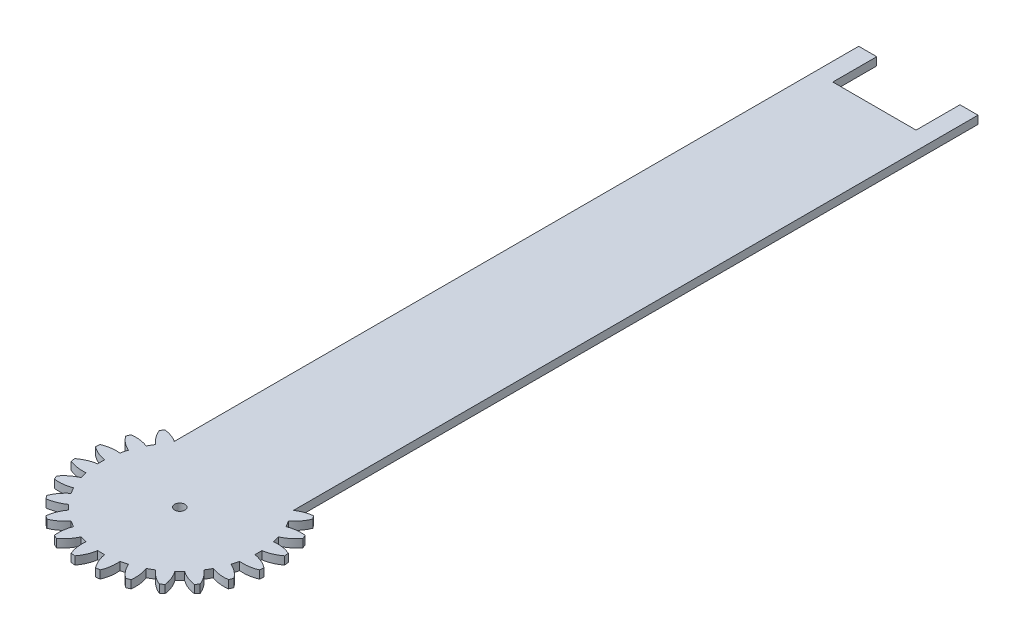
from build123d import *

# Parameters (mm, degrees)
SKETCH1_R           = 1.4
BOSS_EXTRUDE2_DEPTH = 2.2


with BuildPart() as part:
    # Sketch1 → Boss-Extrude2 (new body)
    with BuildSketch(Plane(origin=(0, 0, 0), x_dir=(1, 0, 0), z_dir=(0, 1, 0))):
        with BuildLine():
            Line((16.3, 94), (11.375, 94))
            Line((11.375, 94), (11.375, 82))
            Line((11.375, 82), (-11.375, 82))
            Line((-11.375, 82), (-11.375, 94))
            Line((-11.375, 94), (-16.3, 94))
            Line((-16.3, 94), (-16.3, -93.009457189))
            ThreePointArc((-16.3, -93.009457189), (-18.198030993, -92.065396391), (-20.256978495, -91.560908909))
            ThreePointArc((-20.256978495, -91.560908909), (-20.608541379, -92.008832104), (-20.950210791, -92.464346827))
            ThreePointArc((-20.950210791, -92.464346827), (-19.767163473, -94.547256661), (-18.105269554, -96.272429968))
            ThreePointArc((-18.105269554, -96.272429968), (-18.600034687, -97.087129259), (-19.058202403, -97.922958078))
            ThreePointArc((-19.058202403, -97.922958078), (-21.383193272, -97.34630238), (-23.778569761, -97.363208265))
            ThreePointArc((-23.778569761, -97.363208265), (-24.002222377, -97.886860017), (-24.214353801, -98.415284003))
            ThreePointArc((-24.214353801, -98.415284003), (-22.532521108, -100.121025228), (-20.480747143, -101.357284883))
            ThreePointArc((-20.480747143, -101.357284883), (-20.747793871, -102.272278608), (-20.974021483, -103.198209782))
            ThreePointArc((-20.974021483, -103.198209782), (-23.369039687, -103.242955066), (-25.678420136, -103.879253953))
            ThreePointArc((-25.678420136, -103.879253953), (-25.758920927, -104.442948261), (-25.827057957, -105.008270289))
            ThreePointArc((-25.827057957, -105.008270289), (-23.761054008, -106.220599459), (-21.459225003, -106.88369641))
            ThreePointArc((-21.459225003, -106.88369641), (-21.480354532, -107.836629259), (-21.459225003, -108.789562107))
            ThreePointArc((-21.459225003, -108.789562107), (-23.761054008, -109.452659058), (-25.827057957, -110.664988228))
            ThreePointArc((-25.827057957, -110.664988228), (-25.758920927, -111.230310256), (-25.678420136, -111.794004564))
            ThreePointArc((-25.678420136, -111.794004564), (-23.369039687, -112.430303451), (-20.974021484, -112.475048735))
            ThreePointArc((-20.974021484, -112.475048735), (-20.747793871, -113.400979909), (-20.480747144, -114.315973634))
            ThreePointArc((-20.480747144, -114.315973634), (-22.532521108, -115.552233289), (-24.214353801, -117.257974514))
            ThreePointArc((-24.214353801, -117.257974514), (-24.002222377, -117.7863985), (-23.778569761, -118.310050252))
            ThreePointArc((-23.778569761, -118.310050252), (-21.383193272, -118.326956137), (-19.058202403, -117.750300439))
            ThreePointArc((-19.058202403, -117.750300439), (-18.600034687, -118.586129259), (-18.105269555, -119.40082855))
            ThreePointArc((-18.105269555, -119.40082855), (-19.767163473, -121.126001856), (-20.950210791, -123.20891169))
            ThreePointArc((-20.950210791, -123.20891169), (-20.608541379, -123.664426413), (-20.256978495, -124.112349608))
            ThreePointArc((-20.256978495, -124.112349608), (-17.938846915, -123.508710383), (-15.842327667, -122.349951835))
            ThreePointArc((-15.842327667, -122.349951835), (-15.18344322, -123.038717947), (-14.494677108, -123.697602394))
            ThreePointArc((-14.494677108, -123.697602394), (-15.653435656, -125.794121643), (-16.257074881, -128.112253222))
            ThreePointArc((-16.257074881, -128.112253222), (-15.809151686, -128.463816106), (-15.353636963, -128.805485519))
            ThreePointArc((-15.353636963, -128.805485519), (-13.270727129, -127.6224382), (-11.545553822, -125.960544282))
            ThreePointArc((-11.545553822, -125.960544282), (-10.730854531, -126.455309415), (-9.895025712, -126.91347713))
            ThreePointArc((-9.895025712, -126.91347713), (-10.47168141, -129.238467999), (-10.454775525, -131.633844488))
            ThreePointArc((-10.454775525, -131.633844488), (-9.931123773, -131.857497104), (-9.402699787, -132.069628528))
            ThreePointArc((-9.402699787, -132.069628528), (-7.696958562, -130.387795835), (-6.460698907, -128.336021871))
            ThreePointArc((-6.460698907, -128.336021871), (-5.545705182, -128.603068598), (-4.619774008, -128.829296211))
            ThreePointArc((-4.619774008, -128.829296211), (-4.575028724, -131.224314414), (-3.938729837, -133.533694863))
            ThreePointArc((-3.938729837, -133.533694863), (-3.375035529, -133.614195654), (-2.809713501, -133.682332684))
            ThreePointArc((-2.809713501, -133.682332684), (-1.597384331, -131.616328735), (-0.93428738, -129.31449973))
            ThreePointArc((-0.93428738, -129.31449973), (0.018645469, -129.335629259), (0.971578317, -129.31449973))
            ThreePointArc((0.971578317, -129.31449973), (1.634675268, -131.616328735), (2.847004438, -133.682332684))
            ThreePointArc((2.847004438, -133.682332684), (3.412326466, -133.614195654), (3.976020774, -133.533694863))
            ThreePointArc((3.976020774, -133.533694863), (4.612319661, -131.224314414), (4.657064945, -128.829296211))
            ThreePointArc((4.657064945, -128.829296211), (5.582996119, -128.603068598), (6.497989844, -128.336021871))
            ThreePointArc((6.497989844, -128.336021871), (7.734249499, -130.387795835), (9.439990724, -132.069628528))
            ThreePointArc((9.439990724, -132.069628528), (9.96841471, -131.857497104), (10.492066462, -131.633844488))
            ThreePointArc((10.492066462, -131.633844488), (10.508972347, -129.238467999), (9.932316649, -126.91347713))
            ThreePointArc((9.932316649, -126.91347713), (10.768145469, -126.455309415), (11.582844759, -125.960544282))
            ThreePointArc((11.582844759, -125.960544282), (13.308018066, -127.6224382), (15.3909279, -128.805485518))
            ThreePointArc((15.3909279, -128.805485518), (15.846442623, -128.463816106), (16.294365818, -128.112253222))
            ThreePointArc((16.294365818, -128.112253222), (15.690726593, -125.794121643), (14.531968045, -123.697602394))
            ThreePointArc((14.531968045, -123.697602394), (15.220734157, -123.038717947), (15.879618604, -122.349951835))
            ThreePointArc((15.879618604, -122.349951835), (17.976137853, -123.508710383), (20.294269432, -124.112349608))
            ThreePointArc((20.294269432, -124.112349608), (20.645832316, -123.664426413), (20.987501728, -123.20891169))
            ThreePointArc((20.987501728, -123.20891169), (19.80445441, -121.126001856), (18.142560492, -119.400828549))
            ThreePointArc((18.142560492, -119.400828549), (18.637325625, -118.586129259), (19.09549334, -117.750300439))
            ThreePointArc((19.09549334, -117.750300439), (21.420484209, -118.326956137), (23.815860698, -118.310050252))
            ThreePointArc((23.815860698, -118.310050252), (24.039513314, -117.7863985), (24.251644738, -117.257974514))
            ThreePointArc((24.251644738, -117.257974514), (22.569812045, -115.552233289), (20.518038081, -114.315973634))
            ThreePointArc((20.518038081, -114.315973634), (20.785084808, -113.400979909), (21.011312421, -112.475048735))
            ThreePointArc((21.011312421, -112.475048735), (23.406330624, -112.430303451), (25.715711073, -111.794004564))
            ThreePointArc((25.715711073, -111.794004564), (25.796211864, -111.230310256), (25.864348894, -110.664988228))
            ThreePointArc((25.864348894, -110.664988228), (23.798344945, -109.452659058), (21.49651594, -108.789562107))
            ThreePointArc((21.49651594, -108.789562107), (21.517645469, -107.836629259), (21.49651594, -106.88369641))
            ThreePointArc((21.49651594, -106.88369641), (23.798344945, -106.220599459), (25.864348894, -105.008270289))
            ThreePointArc((25.864348894, -105.008270289), (25.796211864, -104.442948261), (25.715711073, -103.879253953))
            ThreePointArc((25.715711073, -103.879253953), (23.406330624, -103.242955066), (21.011312421, -103.198209782))
            ThreePointArc((21.011312421, -103.198209782), (20.785084808, -102.272278608), (20.518038081, -101.357284883))
            ThreePointArc((20.518038081, -101.357284883), (22.569812045, -100.121025228), (24.251644738, -98.415284003))
            ThreePointArc((24.251644738, -98.415284003), (24.039513314, -97.886860017), (23.815860698, -97.363208265))
            ThreePointArc((23.815860698, -97.363208265), (21.420484209, -97.34630238), (19.09549334, -97.922958078))
            ThreePointArc((19.09549334, -97.922958078), (18.637325625, -97.087129259), (18.142560492, -96.272429968))
            ThreePointArc((18.142560492, -96.272429968), (19.80445441, -94.547256661), (20.987501728, -92.464346827))
            ThreePointArc((20.987501728, -92.464346827), (20.645832316, -92.008832104), (20.294269432, -91.560908909))
            ThreePointArc((20.294269432, -91.560908909), (18.214473173, -92.073055949), (16.3, -93.033597224))
            Line((16.3, -93.033597224), (16.3, 94))
        make_face()
        with Locations((0.018645469, -107.836629259)):
            Circle(SKETCH1_R, mode=Mode.SUBTRACT)
    extrude(amount=BOSS_EXTRUDE2_DEPTH)


solid = part.part
